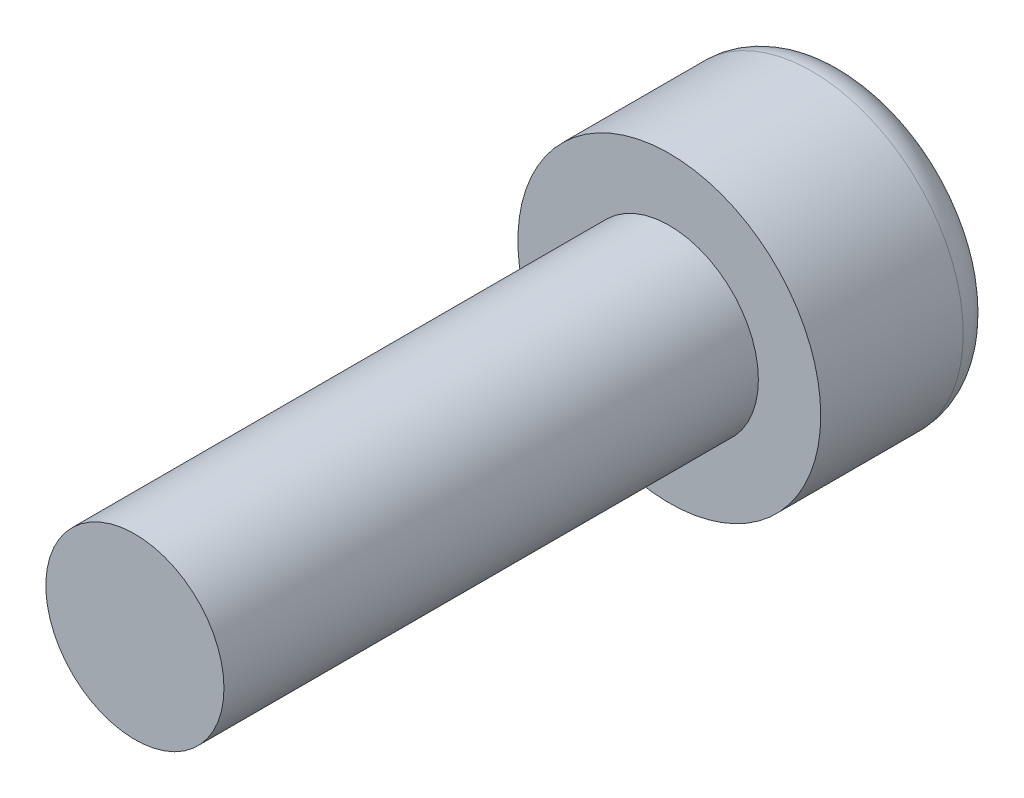
from build123d import *

# Parameters (mm, degrees)
SKETCH_1_R      = 4.25
EXTRUDE_1_DEPTH = 5
SKETCH_2_R      = 2.5
EXTRUDE_2_DEPTH = 15
FILLET_1_R      = 1


with BuildPart() as part:
    # ｽｹｯﾁ1 → ﾎﾞｽ - 押し出し1 (new body)
    with BuildSketch(Plane.XY):
        Circle(SKETCH_1_R)
    extrude(amount=EXTRUDE_1_DEPTH)

    # ｽｹｯﾁ2 → ﾎﾞｽ - 押し出し2 (add)
    with BuildSketch(Plane.XY.offset(5)):
        Circle(SKETCH_2_R)
    extrude(amount=EXTRUDE_2_DEPTH)

    # ﾌｨﾚｯﾄ1
    fillet_1_edges = [part.edges().sort_by_distance(p)[0] for p in [
        (-4.25, 0, 0),
    ]]
    fillet(fillet_1_edges, radius=FILLET_1_R)


solid = part.part
